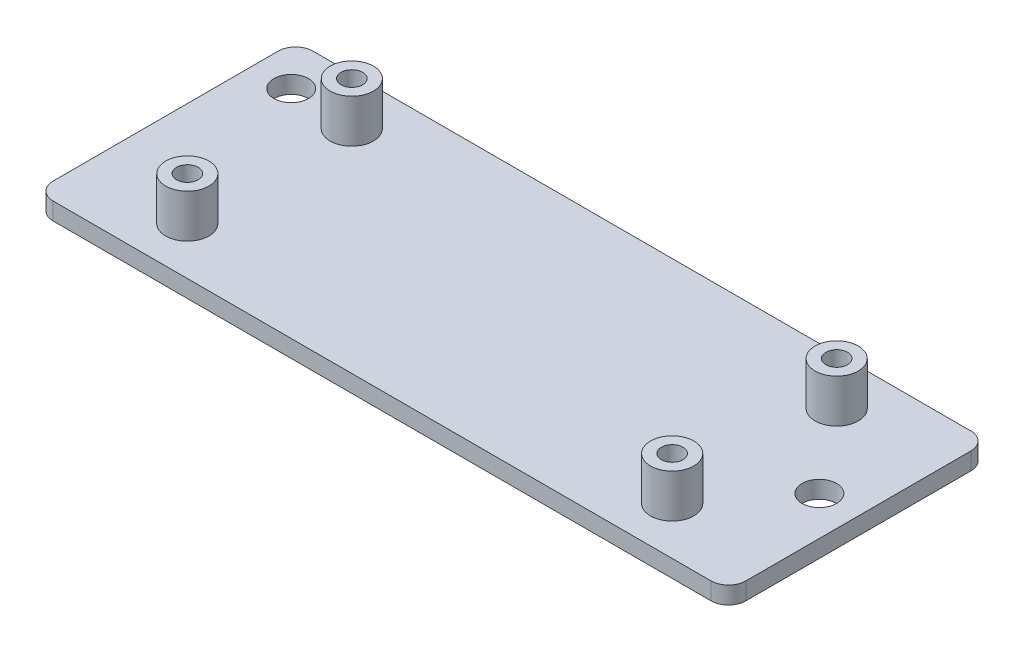
from build123d import *

# Parameters (mm, degrees)
SKETCH_1_W               = 80
SKETCH_1_H               = 30
EXTRUDE_1_DEPTH          = 2
SKETCH_2_R               = 2.5
EXTRUDE_2_DEPTH          = 5
SKETCH_3_R               = 1.25
CUT_EXTRUDE_1_DEPTH      = 1
CUT_EXTRUDE_1_DEPTH_BACK = 8
SKETCH_4_R               = 2
CUT_EXTRUDE_2_DEPTH      = 6
CUT_EXTRUDE_2_DEPTH_BACK = 3
FILLET_1_R               = 2
FILLET_2_R               = 2
FILLET_3_R               = 2
FILLET_4_R               = 2


with BuildPart() as part:
    # Эскиз1 → Бобышка-Вытянуть1 (new body)
    with BuildSketch(Plane(origin=(0, 0, 0), x_dir=(1, 0, 0), z_dir=(0, 1, 0))):
        with Locations((40, -15)):
            Rectangle(SKETCH_1_W, SKETCH_1_H)
    extrude(amount=EXTRUDE_1_DEPTH)

    # Эскиз2 → Бобышка-Вытянуть2 (add)
    with BuildSketch(Plane(origin=(0, 2, 0), x_dir=(1, 0, 0), z_dir=(0, 1, 0))):
        with Locations((12, -5.5)):
            Circle(SKETCH_2_R)
        with Locations((12, -24.5)):
            Circle(SKETCH_2_R)
        with Locations((68, -5.5)):
            Circle(SKETCH_2_R)
        with Locations((68, -24.5)):
            Circle(SKETCH_2_R)
    extrude(amount=EXTRUDE_2_DEPTH)

    # Эскиз3 → Вырез-Вытянуть1 (cut, two sides)
    with BuildSketch(Plane(origin=(0, 7, 0), x_dir=(1, 0, 0), z_dir=(0, 1, 0))) as cut_extrude_1_sk:
        with Locations((12, -5.5)):
            Circle(SKETCH_3_R)
        with Locations((12, -24.5)):
            Circle(SKETCH_3_R)
        with Locations((68, -5.5)):
            Circle(SKETCH_3_R)
        with Locations((68, -24.5)):
            Circle(SKETCH_3_R)
    extrude(amount=CUT_EXTRUDE_1_DEPTH, mode=Mode.SUBTRACT)
    extrude(cut_extrude_1_sk.sketch, amount=-CUT_EXTRUDE_1_DEPTH_BACK, mode=Mode.SUBTRACT)

    # Эскиз4 → Вырез-Вытянуть2 (cut, two sides)
    with BuildSketch(Plane(origin=(0, 2, 0), x_dir=(1, 0, 0), z_dir=(0, 1, 0))) as cut_extrude_2_sk:
        with Locations((4.5, -5)):
            Circle(SKETCH_4_R)
        with Locations((75.5, -15)):
            Circle(SKETCH_4_R)
    extrude(amount=CUT_EXTRUDE_2_DEPTH, mode=Mode.SUBTRACT)
    extrude(cut_extrude_2_sk.sketch, amount=-CUT_EXTRUDE_2_DEPTH_BACK, mode=Mode.SUBTRACT)

    # Скругление1
    fillet_1_edges = [part.edges().sort_by_distance(p)[0] for p in [
        (0, 1, 30),
    ]]
    fillet(fillet_1_edges, radius=FILLET_1_R)

    # Скругление2
    fillet_2_edges = [part.edges().sort_by_distance(p)[0] for p in [
        (0, 1, 0),
    ]]
    fillet(fillet_2_edges, radius=FILLET_2_R)

    # Скругление3
    fillet_3_edges = [part.edges().sort_by_distance(p)[0] for p in [
        (80, 1, 0),
    ]]
    fillet(fillet_3_edges, radius=FILLET_3_R)

    # Скругление4
    fillet_4_edges = [part.edges().sort_by_distance(p)[0] for p in [
        (80, 1, 30),
    ]]
    fillet(fillet_4_edges, radius=FILLET_4_R)


solid = part.part
